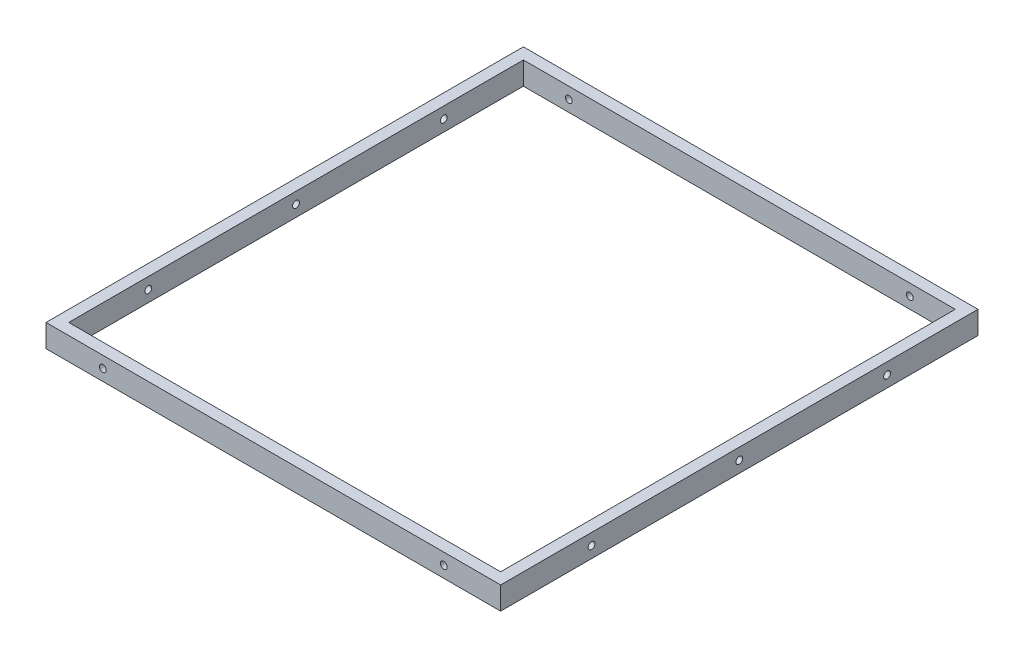
from build123d import *

# Parameters (mm, degrees)
SKETCH1_W           = 400
SKETCH1_H           = 420
SKETCH1_W_2         = 380
SKETCH1_H_2         = 400
BOSS_EXTRUDE1_DEPTH = 20
SKETCH2_R           = 3
CUT_EXTRUDE1_DEPTH  = 400
SKETCH3_R           = 3
CUT_EXTRUDE2_DEPTH  = 420


with BuildPart() as part:
    # Sketch1 → Boss-Extrude1 (new body)
    with BuildSketch(Plane(origin=(0, 0, 0), x_dir=(1, 0, 0), z_dir=(0, 1, 0))):
        Rectangle(SKETCH1_W, SKETCH1_H)
        Rectangle(SKETCH1_W_2, SKETCH1_H_2, mode=Mode.SUBTRACT)
    extrude(amount=BOSS_EXTRUDE1_DEPTH)

    # Sketch2 → Cut-Extrude1 (cut)
    with BuildSketch(Plane.ZY.offset(200)):
        with Locations((1.026e-06, 10)):
            Circle(SKETCH2_R)
        with Locations((129.999998686, 10)):
            Circle(SKETCH2_R)
        with Locations((-130, 10)):
            Circle(SKETCH2_R)
    extrude(amount=-CUT_EXTRUDE1_DEPTH, mode=Mode.SUBTRACT)

    # Sketch3 → Cut-Extrude2 (cut)
    with BuildSketch(Plane(origin=(0, 0, -210), x_dir=(-1, 0, 0), z_dir=(0, 0, -1))):
        with Locations((-150, 10)):
            Circle(SKETCH3_R)
        with Locations((150, 10)):
            Circle(SKETCH3_R)
    extrude(amount=-CUT_EXTRUDE2_DEPTH, mode=Mode.SUBTRACT)


solid = part.part
